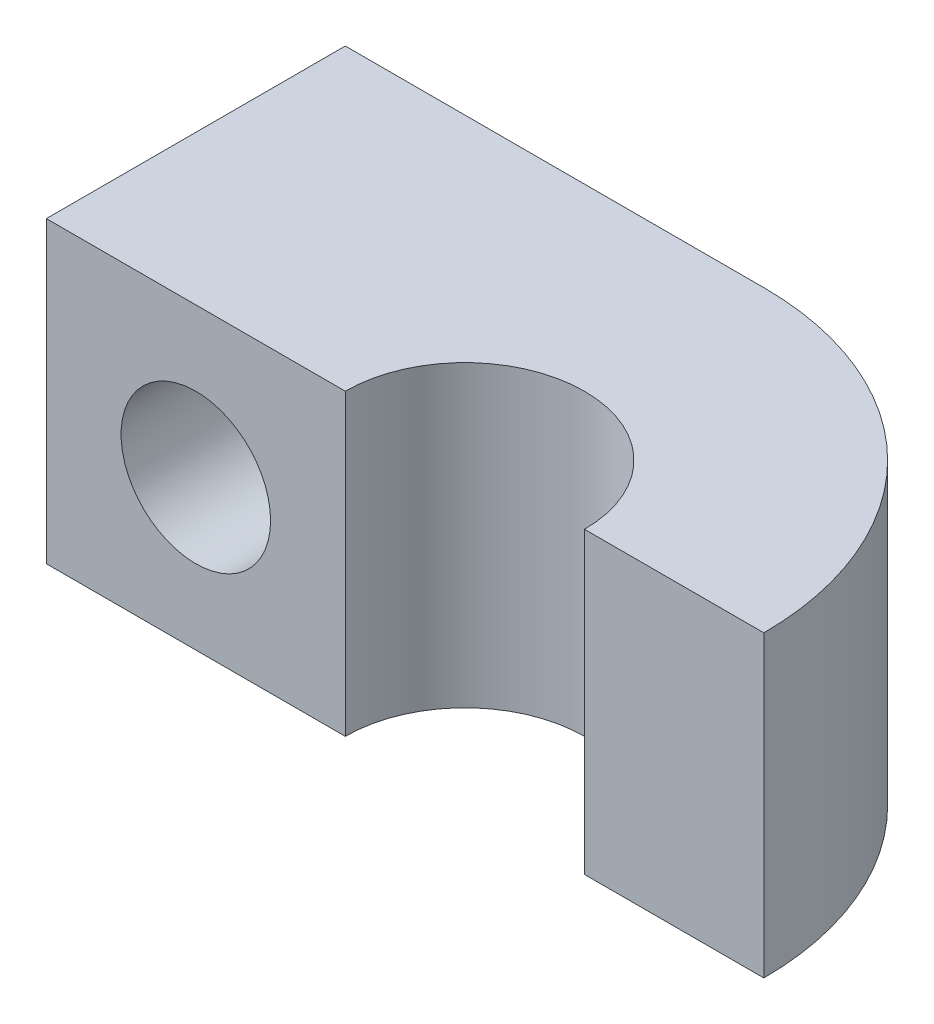
from build123d import *

# Parameters (mm, degrees)
EXTRUDE_1_DEPTH     = 5
SKETCH_2_R          = 1.25
CUT_EXTRUDE_1_DEPTH = 5


with BuildPart() as part:
    # Эскиз1 → Бобышка-Вытянуть1 (new body)
    with BuildSketch(Plane(origin=(0, 0, 0), x_dir=(1, 0, 0), z_dir=(0, 1, 0))):
        with BuildLine():
            Line((2, 0), (5, 0))
            ThreePointArc((5, 0), (3.535533906, 3.535533906), (0, 5))
            Line((0, 5), (-7, 5))
            Line((-7, 5), (-7, 0))
            Line((-7, 0), (-2, 0))
            ThreePointArc((-2, 0), (0, 2), (2, 0))
        make_face()
    extrude(amount=EXTRUDE_1_DEPTH)

    # Эскиз2 → Вырез-Вытянуть1 (cut)
    with BuildSketch(Plane.XY):
        with Locations((-4.5, 2.5)):
            Circle(SKETCH_2_R)
    extrude(amount=-CUT_EXTRUDE_1_DEPTH, mode=Mode.SUBTRACT)


solid = part.part
